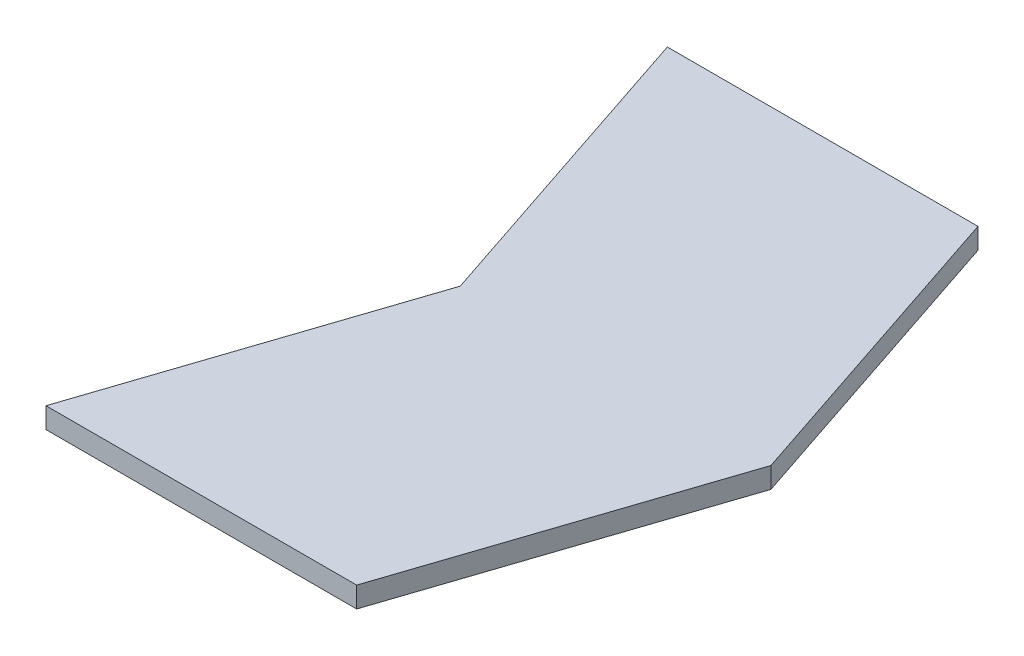
from build123d import *

# Parameters (mm, degrees)
BOSS_EXTRUDE1_DEPTH = 1.27


with BuildPart() as part:
    # Sketch1 → Boss-Extrude1 (new body)
    with BuildSketch(Plane(origin=(0, 0, 0), x_dir=(1, 0, 0), z_dir=(0, 1, 0))):
        Polygon((0, 0), (19.05, 0), (25.4, 19.05), (19.05, 38.1), (0, 38.1), (6.35, 19.05), align=None)
    extrude(amount=BOSS_EXTRUDE1_DEPTH)


solid = part.part
